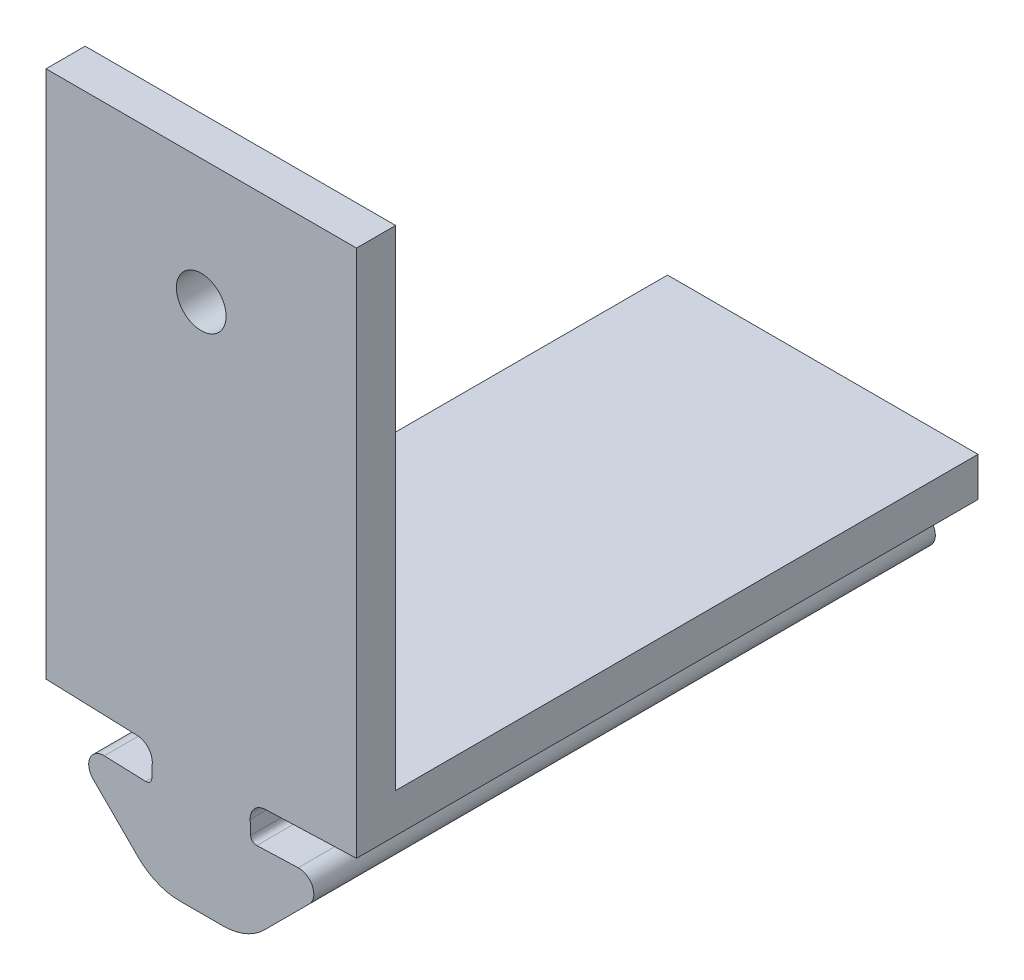
from build123d import *

# Parameters (mm, degrees)
BOSS_EXTRUDE1_DEPTH = 31.75
SKETCH19_W          = 15.860402013
SKETCH19_H          = 31.75
BOSS_EXTRUDE7_DEPTH = 2
SKETCH23_W          = 15.860402013
SKETCH23_H          = 2
BOSS_EXTRUDE8_DEPTH = 25
SKETCH24_R          = 1.27
CUT_EXTRUDE1_DEPTH  = 2.54


with BuildPart() as part:
    # Sketch2 → Boss-Extrude1 (new body)
    with BuildSketch(Plane.XY):
        with BuildLine():
            Line((-50.375618534, 45.609862895), (-50.351188886, 46.309436474))
            ThreePointArc((-50.351188886, 46.309436474), (-50.565618587, 46.88295476), (-51.12278195, 47.136868733))
            Line((-51.12278195, 47.136868733), (-55.780902554, 47.299533889))
            Line((-55.780902554, 47.299533889), (-47.850701548, 47.299533889))
            Line((-47.850701548, 47.299533889), (-47.850701548, 40.900752235))
            Line((-47.850701548, 40.900752235), (-48.952946324, 40.900752235))
            ThreePointArc((-48.952946324, 40.900752235), (-50.100996621, 41.129113637), (-51.074266668, 41.779431891))
            Line((-51.074266668, 41.779431891), (-53.375146928, 44.080312152))
            ThreePointArc((-53.375146928, 44.080312152), (-53.536830204, 44.931922499), (-52.803734096, 45.394471696))
            Line((-52.803734096, 45.394471696), (-50.685905631, 45.320515496))
            ThreePointArc((-50.685905631, 45.320515496), (-50.470836274, 45.400926634), (-50.375618534, 45.609862895))
        make_face()
    boss_extrude1 = extrude(amount=BOSS_EXTRUDE1_DEPTH)

    # Mirror2: Boss-Extrude1 across plane
    add(boss_extrude1.mirror(Plane(origin=(-47.850701548, 40.900752235, 31.75), x_dir=(0, 0, 1), z_dir=(-1, 0, 0))))

    # Sketch19 → Boss-Extrude7 (add)
    with BuildSketch(Plane(origin=(0, 47.299533889, 0), x_dir=(1, 0, 0), z_dir=(0, 1, 0))):
        with Locations((-47.850701548, -15.875)):
            Rectangle(SKETCH19_W, SKETCH19_H)
    extrude(amount=BOSS_EXTRUDE7_DEPTH)

    # Sketch23 → Boss-Extrude8 (add)
    with BuildSketch(Plane(origin=(0, 49.299533889, 0), x_dir=(1, 0, 0), z_dir=(0, 1, 0))):
        with Locations((-47.850701548, -30.75)):
            Rectangle(SKETCH23_W, SKETCH23_H)
    extrude(amount=BOSS_EXTRUDE8_DEPTH)

    # Sketch24 → Cut-Extrude1 (cut)
    with BuildSketch(Plane(origin=(0, 0, 29.75), x_dir=(-1, 0, 0), z_dir=(0, 0, -1))):
        with Locations((47.850701548, 67.949533889)):
            Circle(SKETCH24_R)
    extrude(amount=-CUT_EXTRUDE1_DEPTH, mode=Mode.SUBTRACT)


solid = part.part
